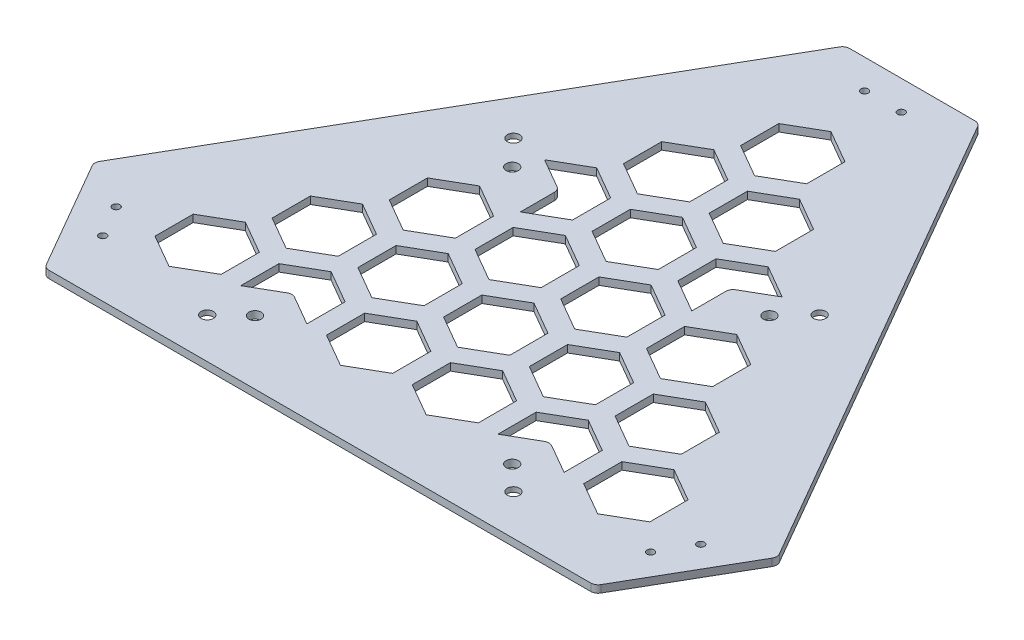
from build123d import *

# Parameters (mm, degrees)
EXTRUDE_1_DEPTH           = 3
CUT_EXTRUDE_1_DEPTH       = 4
CUT_EXTRUDE_2_DEPTH       = 4
CUT_EXTRUDE_3_DEPTH       = 4
CUT_EXTRUDE_4_DEPTH       = 4
CUT_EXTRUDE_5_DEPTH       = 4
CUT_EXTRUDE_6_DEPTH       = 4
CUT_EXTRUDE_7_DEPTH       = 4
CUT_EXTRUDE_8_DEPTH       = 4
CUT_EXTRUDE_9_DEPTH       = 4
CUT_EXTRUDE_10_DEPTH      = 4
CUT_EXTRUDE_11_DEPTH      = 4
CUT_EXTRUDE_12_DEPTH      = 4
CUT_EXTRUDE_13_DEPTH      = 4
CUT_EXTRUDE_14_DEPTH      = 4
CUT_EXTRUDE_15_DEPTH      = 4
CUT_EXTRUDE_16_DEPTH      = 4
CUT_EXTRUDE_17_DEPTH      = 4
CUT_EXTRUDE_18_DEPTH      = 4
CUT_EXTRUDE_19_DEPTH      = 4
CUT_EXTRUDE_20_DEPTH      = 4
CUT_EXTRUDE_21_DEPTH      = 4
HOLE_WIZARD_1_D           = 5
HOLE_WIZARD_1_DEPTH       = 3
HOLE_WIZARD_1_CBORE_D     = 11
HOLE_WIZARD_1_CBORE_DEPTH = 1
HOLE_WIZARD_3_0_3_1_D     = 3
HOLE_WIZARD_3_0_3_1_DEPTH = 3
HOLE_WIZARD_5_0_5_1_D     = 5
HOLE_WIZARD_5_0_5_1_DEPTH = 3


with BuildPart() as part:
    # 草圖1 → 填料-伸長1 (new body)
    with BuildSketch(Plane.XZ.offset(3)):
        with BuildLine():
            Line((28.175426404, -143.950815819), (138.752776596, 47.574772881))
            ThreePointArc((138.752776596, 47.574772881), (139.154700385, 49.074772881), (138.752776596, 50.574772881))
            Line((138.752776596, 50.574772881), (113.175426404, 94.876042937))
            ThreePointArc((113.175426404, 94.876042937), (112.077350192, 95.974119149), (110.577350192, 96.376042937))
            Line((110.577350192, 96.376042937), (-110.577350192, 96.376042937))
            ThreePointArc((-110.577350192, 96.376042937), (-112.077350192, 95.974119149), (-113.175426404, 94.876042937))
            Line((-113.175426404, 94.876042937), (-138.752776596, 50.574772881))
            ThreePointArc((-138.752776596, 50.574772881), (-139.154700385, 49.074772881), (-138.752776596, 47.574772881))
            Line((-138.752776596, 47.574772881), (-28.175426404, -143.950815819))
            ThreePointArc((-28.175426404, -143.950815819), (-27.077350192, -145.04889203), (-25.577350192, -145.450815819))
            Line((-25.577350192, -145.450815819), (25.577350192, -145.450815819))
            ThreePointArc((25.577350192, -145.450815819), (27.077350192, -145.04889203), (28.175426404, -143.950815819))
        make_face()
    extrude(amount=-EXTRUDE_1_DEPTH)

    # 草圖2 → 除料-伸長1 (cut, through all)
    with BuildSketch(Plane.XZ.offset(3)):
        Polygon((21.5, 16.794228634), (35, 9), (48.5, 16.794228634), (48.5, 32.382685902), (35, 40.176914536), (21.5, 32.382685902), align=None)
    extrude(amount=-CUT_EXTRUDE_1_DEPTH, mode=Mode.SUBTRACT)

    # 草圖3 → 除料-伸長2 (cut, through all)
    with BuildSketch(Plane.XZ.offset(3)):
        with BuildLine():
            Line((-48.5, -43.827549631), (-35, -51.621778265))
            Line((-35, -51.621778265), (-21.5, -43.827549631))
            Line((-21.5, -43.827549631), (-21.5, -28.239092363))
            Line((-21.5, -28.239092363), (-35, -20.444863729))
            Line((-35, -20.444863729), (-35, -34.301270189))
            ThreePointArc((-35, -34.301270189), (-35.401923789, -35.801270189), (-36.5, -36.899346401))
            Line((-36.5, -36.899346401), (-48.5, -43.827549631))
        make_face()
    extrude(amount=-CUT_EXTRUDE_2_DEPTH, mode=Mode.SUBTRACT)

    # 草圖4 → 除料-伸長3 (cut, through all)
    with BuildSketch(Plane.XZ.offset(3)):
        Polygon((-13.5, -43.827549631), (0, -51.621778265), (13.5, -43.827549631), (13.5, -28.239092363), (0, -20.444863729), (-13.5, -28.239092363), align=None)
    extrude(amount=-CUT_EXTRUDE_3_DEPTH, mode=Mode.SUBTRACT)

    # 草圖5 → 除料-伸長4 (cut, through all)
    with BuildSketch(Plane.XZ.offset(3)):
        Polygon((39, -13.516660498), (52.5, -21.310889132), (66, -13.516660498), (66, 2.07179677), (52.5, 9.866025404), (39, 2.07179677), align=None)
    extrude(amount=-CUT_EXTRUDE_4_DEPTH, mode=Mode.SUBTRACT)

    # 草圖6 → 除料-伸長5 (cut, through all)
    with BuildSketch(Plane.XZ.offset(3)):
        Polygon((4, -74.138438763), (17.5, -81.932667397), (31, -74.138438763), (31, -58.549981495), (17.5, -50.755752861), (4, -58.549981495), align=None)
    extrude(amount=-CUT_EXTRUDE_5_DEPTH, mode=Mode.SUBTRACT)

    # 草圖7 → 除料-伸長6 (cut, through all)
    with BuildSketch(Plane.XZ.offset(3)):
        Polygon((-31, -74.138438763), (-17.5, -81.932667397), (-4, -74.138438763), (-4, -58.549981495), (-17.5, -50.755752861), (-31, -58.549981495), align=None)
    extrude(amount=-CUT_EXTRUDE_6_DEPTH, mode=Mode.SUBTRACT)

    # 草圖8 → 除料-伸長7 (cut, through all)
    with BuildSketch(Plane.XZ.offset(3)):
        Polygon((4, -13.516660498), (17.5, -21.310889132), (31, -13.516660498), (31, 2.07179677), (17.5, 9.866025404), (4, 2.07179677), align=None)
    extrude(amount=-CUT_EXTRUDE_7_DEPTH, mode=Mode.SUBTRACT)

    # 草圖9 → 除料-伸長8 (cut, through all)
    with BuildSketch(Plane.XZ.offset(3)):
        Polygon((56.5, 16.794228634), (70, 9), (83.5, 16.794228634), (83.5, 32.382685902), (70, 40.176914536), (56.5, 32.382685902), align=None)
    extrude(amount=-CUT_EXTRUDE_8_DEPTH, mode=Mode.SUBTRACT)

    # 草圖10 → 除料-伸長9 (cut, through all)
    with BuildSketch(Plane.XZ.offset(3)):
        Polygon((-13.5, 16.794228634), (0, 9), (13.5, 16.794228634), (13.5, 32.382685902), (0, 40.176914536), (-13.5, 32.382685902), align=None)
    extrude(amount=-CUT_EXTRUDE_9_DEPTH, mode=Mode.SUBTRACT)

    # 草圖11 → 除料-伸長10 (cut, through all)
    with BuildSketch(Plane.XZ.offset(3)):
        with BuildLine():
            Line((39, 62.693575035), (39, 47.105117767))
            Line((39, 47.105117767), (52.5, 39.310889132))
            Line((52.5, 39.310889132), (66, 47.105117767))
            Line((66, 47.105117767), (66, 62.693575035))
            Line((66, 62.693575035), (54, 55.765371804))
            ThreePointArc((54, 55.765371804), (52.5, 55.363448016), (51, 55.765371804))
            Line((51, 55.765371804), (39, 62.693575035))
        make_face()
    extrude(amount=-CUT_EXTRUDE_10_DEPTH, mode=Mode.SUBTRACT)

    # 草圖12 → 除料-伸長11 (cut, through all)
    with BuildSketch(Plane.XZ.offset(3)):
        Polygon((-48.5, 16.794228634), (-35, 9), (-21.5, 16.794228634), (-21.5, 32.382685902), (-35, 40.176914536), (-48.5, 32.382685902), align=None)
    extrude(amount=-CUT_EXTRUDE_11_DEPTH, mode=Mode.SUBTRACT)

    # 草圖13 → 除料-伸長12 (cut, through all)
    with BuildSketch(Plane.XZ.offset(3)):
        Polygon((-83.5, 16.794228634), (-70, 9), (-56.5, 16.794228634), (-56.5, 32.382685902), (-70, 40.176914536), (-83.5, 32.382685902), align=None)
    extrude(amount=-CUT_EXTRUDE_12_DEPTH, mode=Mode.SUBTRACT)

    # 草圖14 → 除料-伸長13 (cut, through all)
    with BuildSketch(Plane.XZ.offset(3)):
        with BuildLine():
            Line((35, -20.444863729), (21.5, -28.239092363))
            Line((21.5, -28.239092363), (21.5, -43.827549631))
            Line((21.5, -43.827549631), (35, -51.621778265))
            Line((35, -51.621778265), (48.5, -43.827549631))
            Line((48.5, -43.827549631), (36.5, -36.899346401))
            ThreePointArc((36.5, -36.899346401), (35.401923789, -35.801270189), (35, -34.301270189))
            Line((35, -34.301270189), (35, -20.444863729))
        make_face()
    extrude(amount=-CUT_EXTRUDE_13_DEPTH, mode=Mode.SUBTRACT)

    # 草圖15 → 除料-伸長14 (cut, through all)
    with BuildSketch(Plane.XZ.offset(3)):
        Polygon((-66, -13.516660498), (-52.5, -21.310889132), (-39, -13.516660498), (-39, 2.07179677), (-52.5, 9.866025404), (-66, 2.07179677), align=None)
    extrude(amount=-CUT_EXTRUDE_14_DEPTH, mode=Mode.SUBTRACT)

    # 草圖16 → 除料-伸長15 (cut, through all)
    with BuildSketch(Plane.XZ.offset(3)):
        Polygon((-31, -13.516660498), (-17.5, -21.310889132), (-4, -13.516660498), (-4, 2.07179677), (-17.5, 9.866025404), (-31, 2.07179677), align=None)
    extrude(amount=-CUT_EXTRUDE_15_DEPTH, mode=Mode.SUBTRACT)

    # 草圖17 → 除料-伸長16 (cut, through all)
    with BuildSketch(Plane.XZ.offset(3)):
        Polygon((-101, 47.105117767), (-87.5, 39.310889132), (-74, 47.105117767), (-74, 62.693575035), (-87.5, 70.487803669), (-101, 62.693575035), align=None)
    extrude(amount=-CUT_EXTRUDE_16_DEPTH, mode=Mode.SUBTRACT)

    # 草圖18 → 除料-伸長17 (cut, through all)
    with BuildSketch(Plane.XZ.offset(3)):
        Polygon((-31, 47.105117767), (-17.5, 39.310889132), (-4, 47.105117767), (-4, 62.693575035), (-17.5, 70.487803669), (-31, 62.693575035), align=None)
    extrude(amount=-CUT_EXTRUDE_17_DEPTH, mode=Mode.SUBTRACT)

    # 草圖19 → 除料-伸長18 (cut, through all)
    with BuildSketch(Plane.XZ.offset(3)):
        Polygon((74, 47.105117767), (87.5, 39.310889132), (101, 47.105117767), (101, 62.693575035), (87.5, 70.487803669), (74, 62.693575035), align=None)
    extrude(amount=-CUT_EXTRUDE_18_DEPTH, mode=Mode.SUBTRACT)

    # 草圖20 → 除料-伸長19 (cut, through all)
    with BuildSketch(Plane.XZ.offset(3)):
        Polygon((4, 47.105117767), (17.5, 39.310889132), (31, 47.105117767), (31, 62.693575035), (17.5, 70.487803669), (4, 62.693575035), align=None)
    extrude(amount=-CUT_EXTRUDE_19_DEPTH, mode=Mode.SUBTRACT)

    # 草圖21 → 除料-伸長20 (cut, through all)
    with BuildSketch(Plane.XZ.offset(3)):
        Polygon((-13.5, -104.449327896), (0, -112.24355653), (13.5, -104.449327896), (13.5, -88.860870628), (0, -81.066641994), (-13.5, -88.860870628), align=None)
    extrude(amount=-CUT_EXTRUDE_20_DEPTH, mode=Mode.SUBTRACT)

    # 草圖22 → 除料-伸長21 (cut, through all)
    with BuildSketch(Plane(origin=(0, 0, 0), x_dir=(-1, 0, 0), z_dir=(0, 1, 0))):
        with BuildLine():
            Line((39, 62.693575035), (39, 47.105117767))
            Line((39, 47.105117767), (52.5, 39.310889132))
            Line((52.5, 39.310889132), (66, 47.105117767))
            Line((66, 47.105117767), (66, 62.693575035))
            Line((66, 62.693575035), (54, 55.765371804))
            ThreePointArc((54, 55.765371804), (52.5, 55.363448016), (51, 55.765371804))
            Line((51, 55.765371804), (39, 62.693575035))
        make_face()
    extrude(amount=-CUT_EXTRUDE_21_DEPTH, mode=Mode.SUBTRACT)

    # 鑽孔1
    with Locations(Plane(origin=(0, -3, 0), x_dir=(-1, 0, 0), z_dir=(0, -1, 0))):
        with Locations((62.5, 45.123957063), (-62.5, 45.123957063), (-62.5, -79.876042937), (62.5, -79.876042937)):
            CounterBoreHole(HOLE_WIZARD_1_D / 2, HOLE_WIZARD_1_CBORE_D / 2, HOLE_WIZARD_1_CBORE_DEPTH, depth=HOLE_WIZARD_1_DEPTH)

    # Ø3.0 (3) 直徑孔1
    with Locations(Plane(origin=(0, 0, 0), x_dir=(1, 0, 0), z_dir=(0, 1, 0))):
        with Locations((111.821796655, -73.220598438), (119.321796655, -60.230217381), (7.5, 133.450815819), (-7.5, 133.450815819), (-111.821796655, -73.220598438), (-119.321796655, -60.230217381)):
            Hole(HOLE_WIZARD_3_0_3_1_D / 2, depth=HOLE_WIZARD_3_0_3_1_DEPTH)

    # Ø5.0 (5) 直徑孔1
    with Locations(Plane(origin=(0, -3, 0), x_dir=(-1, 0, 0), z_dir=(0, -1, 0))):
        with Locations((52.5, 34.623957063), (-52.5, 34.623957063), (-52.5, -70.376042937), (52.5, -70.376042937)):
            Hole(HOLE_WIZARD_5_0_5_1_D / 2, depth=HOLE_WIZARD_5_0_5_1_DEPTH)


solid = part.part
